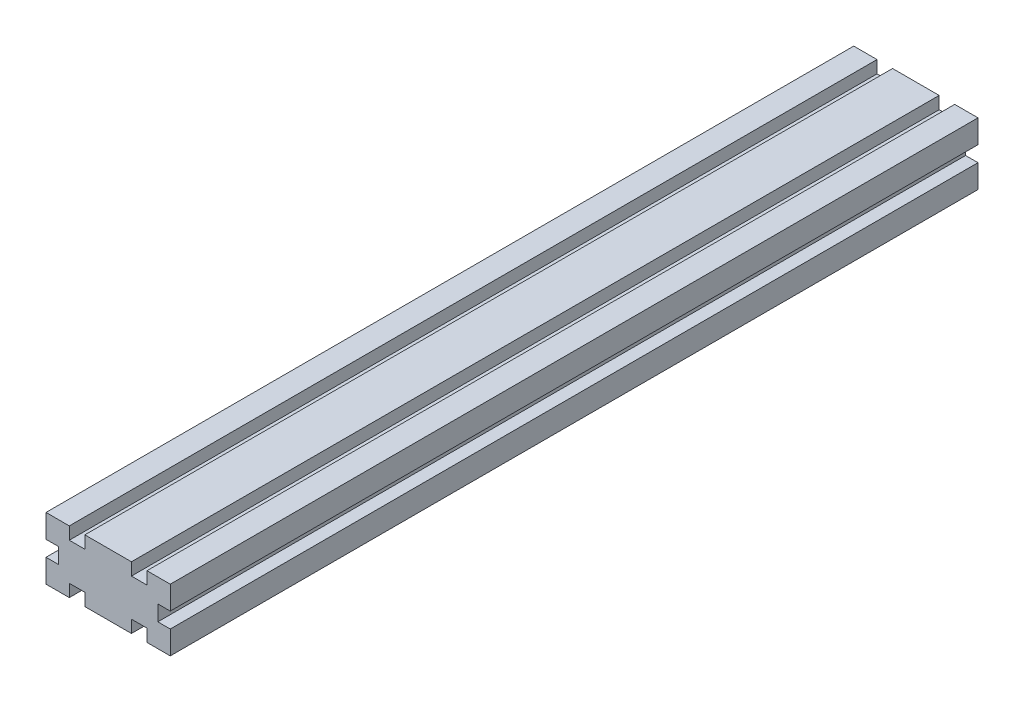
from build123d import *

# Parameters (mm, degrees)
ESQUISSE1_W        = 3.5
ESQUISSE1_H        = 5
ESQUISSE1_W_2      = 5
ESQUISSE1_H_2      = 3.5
ESQUISSE1_W_3      = 4
BOSS_EXTRU_1_DEPTH = 260


with BuildPart() as part:
    # Esquisse1 → Boss.-Extru.1 (new body)
    with BuildSketch(Plane.XY):
        Polygon((7.5, 16), (7.5, 20), (0, 20), (4, 16), align=None)
        Polygon((4, 16), (0, 20), (0, 12.5), (4, 12.5), align=None)
        Polygon((4, 7.5), (0, 7.5), (0, 0), (4, 4), align=None)
        Polygon((0, 0), (7.5, 0), (7.5, 4), (4, 4), align=None)
        Polygon((4, 4), (7.5, 7.5), (4, 7.5), align=None)
        Polygon((7.5, 4), (7.5, 7.5), (4, 4), align=None)
        Polygon((4, 12.5), (7.5, 12.5), (4, 16), align=None)
        Polygon((7.5, 12.5), (7.5, 16), (4, 16), align=None)
        with Locations((5.75, 10)):
            Rectangle(ESQUISSE1_W, ESQUISSE1_H)
        Polygon((7.5, 7.5), (10, 10), (7.5, 12.5), align=None)
        Polygon((10, 10), (12.5, 12.5), (7.5, 12.5), align=None)
        Polygon((12.5, 7.5), (12.5, 12.5), (10, 10), align=None)
        Polygon((12.5, 7.5), (10, 10), (7.5, 7.5), align=None)
        Polygon((16, 4), (12.5, 7.5), (12.5, 4), align=None)
        Polygon((16, 4), (16, 7.5), (12.5, 7.5), align=None)
        Polygon((20, 0), (20, 7.5), (16, 7.5), (16, 4), align=None)
        with Locations((10, 14.25)):
            Rectangle(ESQUISSE1_W_2, ESQUISSE1_H_2)
        with Locations((14.25, 10)):
            Rectangle(ESQUISSE1_W, ESQUISSE1_H)
        Polygon((12.5, 12.5), (16, 16), (12.5, 16), align=None)
        Polygon((16, 16), (20, 20), (12.5, 20), (12.5, 16), align=None)
        Polygon((16, 12.5), (16, 16), (12.5, 12.5), align=None)
        Polygon((20, 12.5), (20, 20), (16, 16), (16, 12.5), align=None)
        Polygon((12.5, 0), (20, 0), (16, 4), (12.5, 4), align=None)
        with Locations((10, 5.75)):
            Rectangle(ESQUISSE1_W_2, ESQUISSE1_H_2)
        with Locations((18, 10)):
            Rectangle(ESQUISSE1_W_3, ESQUISSE1_H)
        with Locations((22, 10)):
            Rectangle(ESQUISSE1_W_3, ESQUISSE1_H)
        Polygon((24, 16), (20, 20), (20, 12.5), (24, 12.5), align=None)
        Polygon((27.5, 20), (20, 20), (24, 16), (27.5, 16), align=None)
        Polygon((27.5, 12.5), (24, 16), (24, 12.5), align=None)
        Polygon((27.5, 16), (24, 16), (27.5, 12.5), align=None)
        with Locations((25.75, 10)):
            Rectangle(ESQUISSE1_W, ESQUISSE1_H)
        Polygon((27.5, 7.5), (24, 7.5), (24, 4), align=None)
        Polygon((24, 7.5), (20, 7.5), (20, 0), (24, 4), align=None)
        Polygon((24, 4), (20, 0), (27.5, 0), (27.5, 4), align=None)
        Polygon((27.5, 4), (27.5, 7.5), (24, 4), align=None)
        with Locations((30, 5.75)):
            Rectangle(ESQUISSE1_W_2, ESQUISSE1_H_2)
        Polygon((36, 4), (32.5, 7.5), (32.5, 4), align=None)
        Polygon((36, 7.5), (32.5, 7.5), (36, 4), align=None)
        Polygon((40, 0), (40, 7.5), (36, 7.5), (36, 4), align=None)
        Polygon((32.5, 4), (32.5, 0), (40, 0), (36, 4), align=None)
        with Locations((34.25, 10)):
            Rectangle(ESQUISSE1_W, ESQUISSE1_H)
        Polygon((32.5, 12.5), (30, 10), (32.5, 7.5), align=None)
        Polygon((32.5, 7.5), (30, 10), (27.5, 7.5), align=None)
        Polygon((30, 10), (27.5, 12.5), (27.5, 7.5), align=None)
        Polygon((32.5, 12.5), (27.5, 12.5), (30, 10), align=None)
        Polygon((36, 16), (32.5, 12.5), (36, 12.5), align=None)
        Polygon((36, 16), (32.5, 16), (32.5, 12.5), align=None)
        Polygon((40, 20), (32.5, 20), (32.5, 16), (36, 16), align=None)
        Polygon((40, 12.5), (40, 20), (36, 16), (36, 12.5), align=None)
        with Locations((30, 14.25)):
            Rectangle(ESQUISSE1_W_2, ESQUISSE1_H_2)
    extrude(amount=BOSS_EXTRU_1_DEPTH)


solid = part.part
